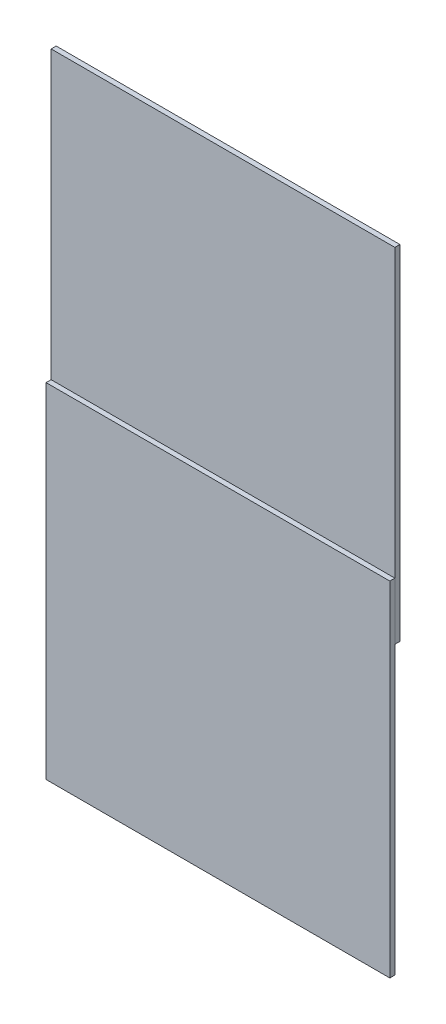
from build123d import *

# Parameters (mm, degrees)
SKIZZE2_W                       = 150
SKIZZE2_H                       = 150
AUFSATZ_LINEAR_AUSTRAGEN1_DEPTH = 2.2
SKIZZE3_W                       = 150
SKIZZE3_H                       = 150
AUFSATZ_LINEAR_AUSTRAGEN3_DEPTH = 2.2
SKIZZE4_W                       = 1
SKIZZE4_H                       = 25
AUFSATZ_LINEAR_AUSTRAGEN4_DEPTH = 1


with BuildPart() as part:
    # Skizze2 → Aufsatz-Linear austragen1 (new body)
    with BuildSketch(Plane.XY):
        with Locations((75, -75)):
            Rectangle(SKIZZE2_W, SKIZZE2_H)
    extrude(amount=AUFSATZ_LINEAR_AUSTRAGEN1_DEPTH)


with BuildPart() as body_2:
    # Skizze3 → Aufsatz-Linear austragen3 (new body)
    with BuildSketch(Plane(origin=(0, 0, 0), x_dir=(-1, 0, 0), z_dir=(0, 0, -1))):
        with Locations((-75, 50)):
            Rectangle(SKIZZE3_W, SKIZZE3_H)
    extrude(amount=AUFSATZ_LINEAR_AUSTRAGEN3_DEPTH)

    # Skizze4 → Aufsatz-Linear austragen4 (add)
    with BuildSketch(Plane(origin=(0, 0, -2.2), x_dir=(-1, 0, 0), z_dir=(0, 0, -1))):
        with Locations((-65.497224617, -12.5)):
            Rectangle(SKIZZE4_W, SKIZZE4_H)
    extrude(amount=AUFSATZ_LINEAR_AUSTRAGEN4_DEPTH)


solid = Compound([part.part, body_2.part])
